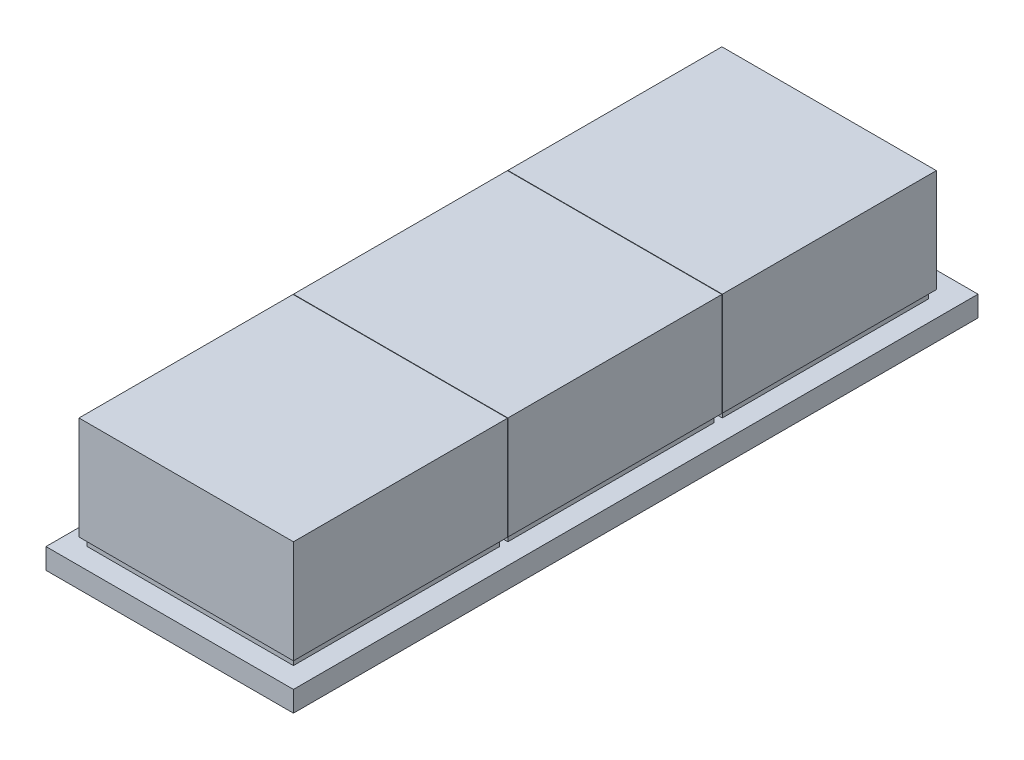
from build123d import *

# Parameters (mm, degrees)
SKETCH1_W           = 60
SKETCH1_H           = 166
BOSS_EXTRUDE1_DEPTH = 5
SKETCH2_W           = 50
SKETCH2_H           = 50
BOSS_EXTRUDE3_DEPTH = 2
LPATTERN1_COUNT     = 3
LPATTERN1_PITCH     = 52
SKETCH3_W           = 52
SKETCH3_H           = 51.9
BOSS_EXTRUDE8_DEPTH = 25
LPATTERN5_COUNT     = 3
LPATTERN5_PITCH     = 52


with BuildPart() as part:
    # Sketch1 → Boss-Extrude1 (new body)
    with BuildSketch(Plane(origin=(0, 0, 0), x_dir=(1, 0, 0), z_dir=(0, 1, 0))):
        Rectangle(SKETCH1_W, SKETCH1_H)
    extrude(amount=BOSS_EXTRUDE1_DEPTH)

    # Sketch2 → Boss-Extrude3 (add)
    with BuildSketch(Plane(origin=(0, 5, 0), x_dir=(1, 0, 0), z_dir=(0, 1, 0))):
        with Locations((0, -53)):
            Rectangle(SKETCH2_W, SKETCH2_H)
    boss_extrude3 = extrude(amount=BOSS_EXTRUDE3_DEPTH)

    # LPattern1: Boss-Extrude3 ×3
    with Locations(*[(0, 0, -i * LPATTERN1_PITCH) for i in range(1, LPATTERN1_COUNT)]):
        add(boss_extrude3)

    # Sketch3 → Boss-Extrude8 (add)
    with BuildSketch(Plane(origin=(0, 7, 0), x_dir=(1, 0, 0), z_dir=(0, 1, 0))):
        with Locations((0, -53.05)):
            Rectangle(SKETCH3_W, SKETCH3_H)
    boss_extrude8 = extrude(amount=BOSS_EXTRUDE8_DEPTH)

    # LPattern5: Boss-Extrude8 ×3
    with Locations(*[(0, 0, -i * LPATTERN5_PITCH) for i in range(1, LPATTERN5_COUNT)]):
        add(boss_extrude8)


solid = part.part
